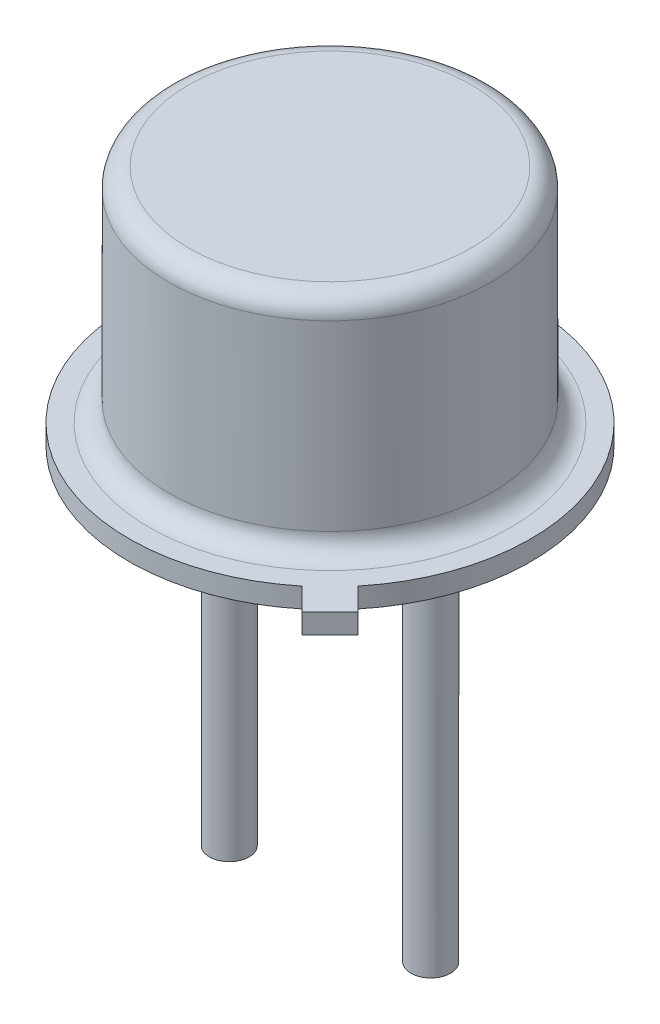
from build123d import *

# Parameters (mm, degrees)
SKETCH_R   = 4.064
BODY_DEPTH = 6.1
SKETCH1_R  = 0.5
LEGS_DEPTH = 10
LIP_DEPTH  = 0.5
FILLET2_R  = 0.5


with BuildPart() as part:
    # sketch → Body (new body)
    with BuildSketch(Plane(origin=(0, 4.06, 0), x_dir=(1, 0, 0), z_dir=(0, 1, 0))):
        with Locations((-2.54, 0)):
            Circle(SKETCH_R)
    extrude(amount=BODY_DEPTH)

    # Sketch1 → Legs (add)
    with BuildSketch(Plane.XZ.offset(-4.06)):
        Circle(SKETCH1_R)
        with Locations((-2.54, -2.54)):
            Circle(SKETCH1_R)
        with Locations((-5.08, 0)):
            Circle(SKETCH1_R)
    extrude(amount=LEGS_DEPTH)

    # Sketch3 → Lip (add)
    with BuildSketch(Plane.XZ.offset(-4.06)):
        with BuildLine():
            Line((1.236134349, 4.48324113), (1.94324113, 3.776134349))
            Line((1.94324113, 3.776134349), (1.377555705, 3.210448924))
            ThreePointArc((1.377555705, 3.210448924), (-6.121495847, -3.581495847), (0.670448924, 3.917555705))
            Line((0.670448924, 3.917555705), (1.236134349, 4.48324113))
        make_face()
    extrude(amount=-LIP_DEPTH)

    # Fillet2
    fillet2_edges = [part.edges().sort_by_distance(p)[0] for p in [
        (-6.604, 4.56, 0),
        (-6.604, 10.16, 0),
    ]]
    fillet(fillet2_edges, radius=FILLET2_R)


solid = part.part
